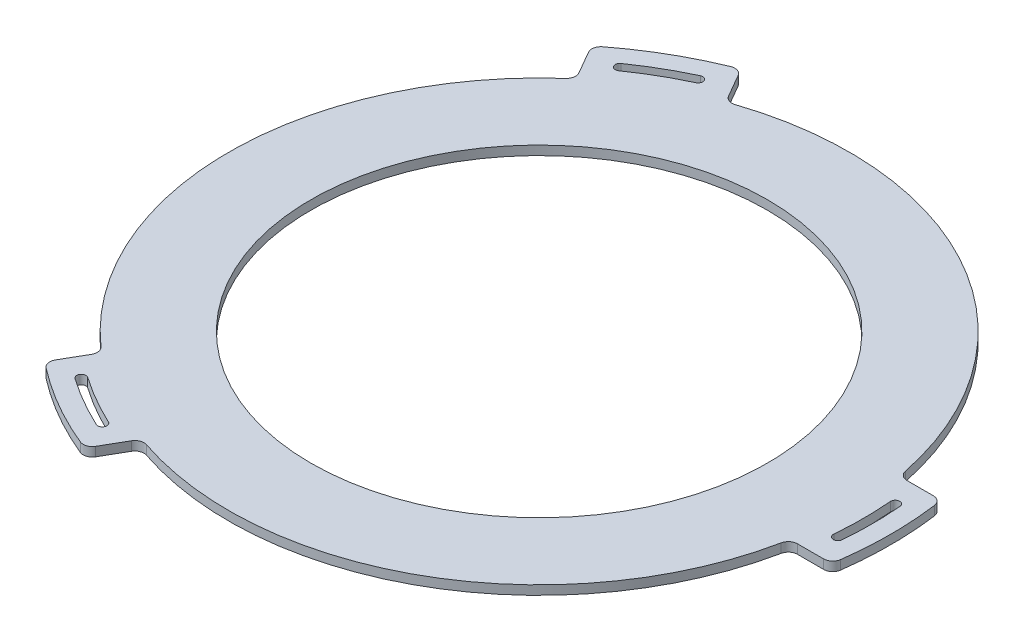
from build123d import *

# Parameters (mm, degrees)
SKETCH1_R           = 340
SKETCH1_R_2         = 250
BOSS_EXTRUDE1_DEPTH = 10
BOSS_EXTRUDE2_DEPTH = 10
FILLET1_R           = 10


with BuildPart() as part:
    # Sketch1 → Boss-Extrude1 (new body)
    with BuildSketch(Plane(origin=(0, 0, 0), x_dir=(1, 0, 0), z_dir=(0, 1, 0))):
        Circle(SKETCH1_R)
        Circle(SKETCH1_R_2, mode=Mode.SUBTRACT)
    extrude(amount=BOSS_EXTRUDE1_DEPTH)

    # Sketch2 → Boss-Extrude2 (add)
    with BuildSketch(Plane.XZ):
        with BuildLine():
            Line((371.651718683, -60), (334.664010614, -60))
            ThreePointArc((334.664010614, -60), (340, 0), (334.664010614, 60))
            Line((334.664010614, 60), (371.651718683, 60))
            ThreePointArc((371.651718683, 60), (378.234524569, 57.527726527), (381.562431181, 51.333333333))
            ThreePointArc((381.562431181, 51.333333333), (385, 0), (381.562431181, -51.333333333))
            ThreePointArc((381.562431181, -51.333333333), (378.234524569, -57.527726527), (371.651718683, -60))
        make_face()
        with BuildLine():
            ThreePointArc((363.611064803, 31.811846103), (365, 0), (363.611064803, -31.811846103))
            ThreePointArc((363.611064803, -31.811846103), (358.194312599, -36.35704088), (353.649117823, -30.940288675))
            ThreePointArc((353.649117823, -30.940288675), (355, 0), (353.649117823, 30.940288675))
            ThreePointArc((353.649117823, 30.940288675), (358.194312599, 36.35704088), (363.611064803, 31.811846103))
        make_face(mode=Mode.SUBTRACT)
        with BuildLine():
            Line((-133.864335114, 351.85982974), (-115.37048108, 319.827534924))
            ThreePointArc((-115.37048108, 319.827534924), (-170, 294.448637287), (-219.293529534, 259.827534924))
            Line((-219.293529534, 259.827534924), (-237.787383569, 291.85982974))
            ThreePointArc((-237.787383569, 291.85982974), (-238.937734879, 298.796843602), (-235.237186318, 304.776091866))
            ThreePointArc((-235.237186318, 304.776091866), (-192.5, 333.419780457), (-146.325244863, 356.109425199))
            ThreePointArc((-146.325244863, 356.109425199), (-139.29678969, 356.324570129), (-133.864335114, 351.85982974))
        make_face()
        with BuildLine():
            ThreePointArc((-209.355399268, 298.990496165), (-210.583277308, 292.026853762), (-203.619634905, 290.798975723))
            ThreePointArc((-203.619634905, 290.798975723), (-177.5, 307.439018343), (-150.029482918, 321.739264398))
            ThreePointArc((-150.029482918, 321.739264398), (-147.611035291, 328.383894642), (-154.255665535, 330.802342268))
            ThreePointArc((-154.255665535, 330.802342268), (-182.5, 316.099272381), (-209.355399268, 298.990496165))
        make_face(mode=Mode.SUBTRACT)
        with BuildLine():
            Line((-237.787383569, -291.85982974), (-219.293529534, -259.827534924))
            ThreePointArc((-219.293529534, -259.827534924), (-170, -294.448637287), (-115.37048108, -319.827534924))
            Line((-115.37048108, -319.827534924), (-133.864335114, -351.85982974))
            ThreePointArc((-133.864335114, -351.85982974), (-139.29678969, -356.324570129), (-146.325244863, -356.109425199))
            ThreePointArc((-146.325244863, -356.109425199), (-192.5, -333.419780457), (-235.237186318, -304.776091866))
            ThreePointArc((-235.237186318, -304.776091866), (-238.937734879, -298.796843602), (-237.787383569, -291.85982974))
        make_face()
        with BuildLine():
            ThreePointArc((-154.255665535, -330.802342268), (-182.5, -316.099272381), (-209.355399268, -298.990496165))
            ThreePointArc((-209.355399268, -298.990496165), (-210.583277308, -292.026853762), (-203.619634905, -290.798975723))
            ThreePointArc((-203.619634905, -290.798975723), (-177.5, -307.439018343), (-150.029482918, -321.739264398))
            ThreePointArc((-150.029482918, -321.739264398), (-147.611035291, -328.383894642), (-154.255665535, -330.802342268))
        make_face(mode=Mode.SUBTRACT)
    extrude(amount=-BOSS_EXTRUDE2_DEPTH)

    # Fillet1
    fillet1_edges = [part.edges().sort_by_distance(p)[0] for p in [
        (334.664010614, 5, -60),
        (334.664010614, 5, 60),
        (-115.37048108, 5, 319.827534924),
        (-219.293529534, 5, 259.827534924),
        (-219.293529534, 5, -259.827534924),
        (-115.37048108, 5, -319.827534924),
    ]]
    fillet(fillet1_edges, radius=FILLET1_R)


solid = part.part
